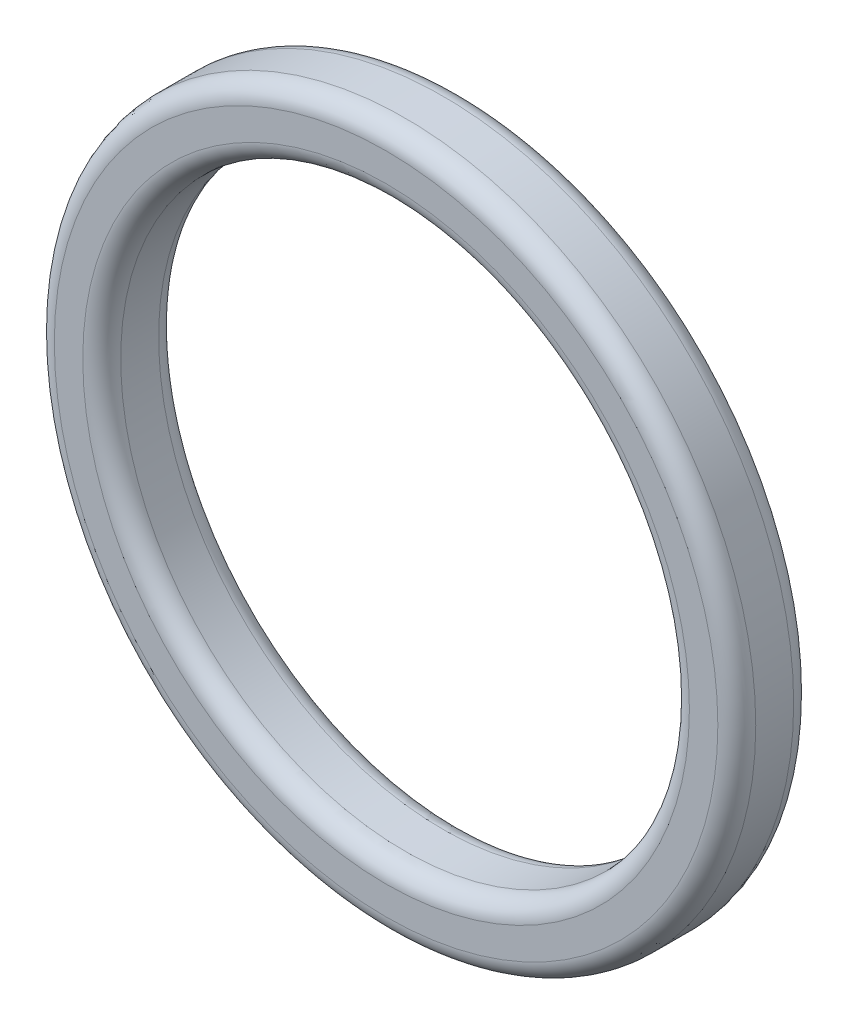
from build123d import *

# Parameters (mm, degrees)
SKETCH_1_R      = 18.5
SKETCH_1_R_2    = 15
EXTRUDE_1_DEPTH = 4
FILLET_1_R      = 1


with BuildPart() as part:
    # 草图1 → 凸台-拉伸1 (new body)
    with BuildSketch(Plane.XY):
        Circle(SKETCH_1_R)
        Circle(SKETCH_1_R_2, mode=Mode.SUBTRACT)
    extrude(amount=EXTRUDE_1_DEPTH)

    # 圆角1
    fillet_1_edges = [part.edges().sort_by_distance(p)[0] for p in [
        (-18.5, 0, 0),
        (-18.5, 0, 4),
        (-15, 0, 0),
        (-15, 0, 4),
    ]]
    fillet(fillet_1_edges, radius=FILLET_1_R)


solid = part.part
